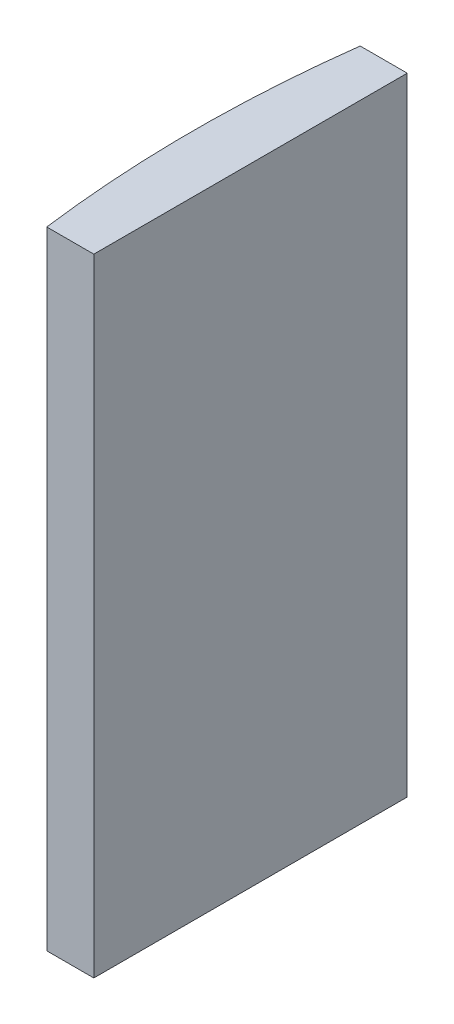
from build123d import *

# Parameters (mm, degrees)
EXTRUDE_1_DEPTH = 40


with BuildPart() as part:
    # 草图1 → 凸台-拉伸1 (new body)
    with BuildSketch(Plane(origin=(0, 0, 0), x_dir=(1, 0, 0), z_dir=(0, 1, 0))):
        with BuildLine():
            Line((-72.547347638, 10), (-69.544795665, 10))
            Line((-69.544795665, 10), (-69.544795665, -10))
            Line((-69.544795665, -10), (-72.547347638, -10))
            ThreePointArc((-72.547347638, -10), (-73.194795665, 0), (-72.547347638, 10))
        make_face()
    extrude(amount=EXTRUDE_1_DEPTH)


solid = part.part
